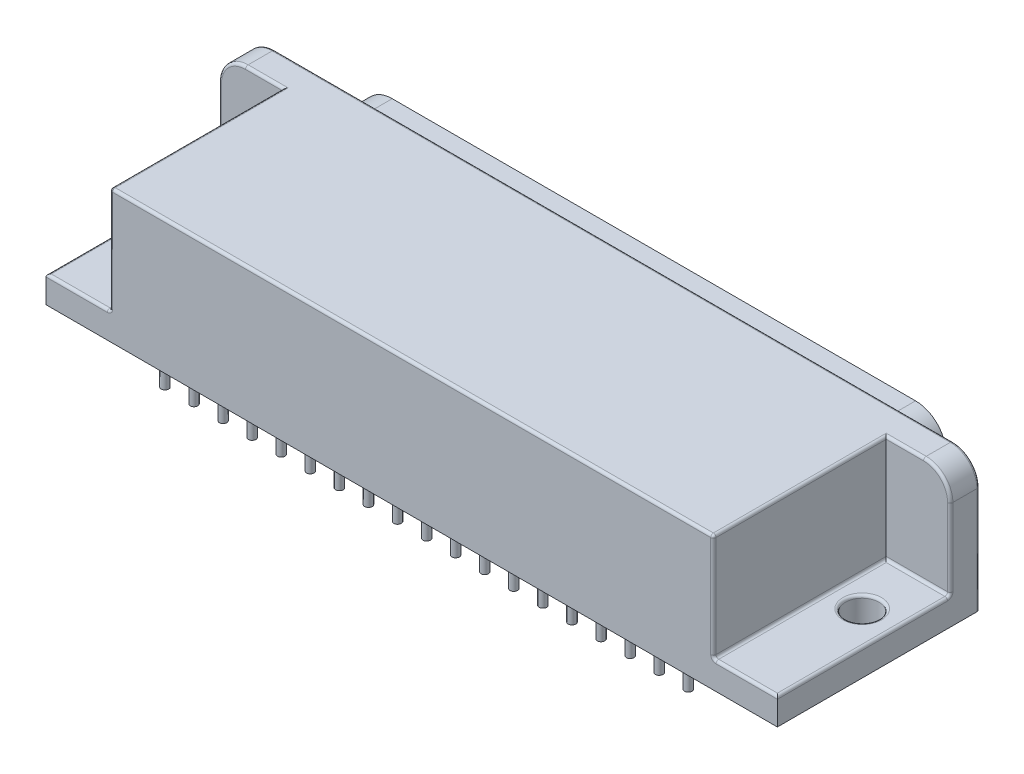
from build123d import *

# Parameters (mm, degrees)
SKETCH1_W              = 69.6468
SKETCH1_H              = 19.2532
BASE_EXTRUDE_DEPTH     = 12.7
BOSS_EXTRUDE1_DEPTH    = 3.81
CUT_EXTRUDE5_DEPTH     = 3.81
SKETCH4_R              = 0.508
BOSS_EXTRUDE4_DEPTH    = 3.81
FILLET7_R              = 0.4826
LPATTERN5_COUNT        = 19
LPATTERN5_PITCH        = 2.7686
FILLET7_OF_LPATTERN5_R = 0.4826
SKETCH5_R              = 0.508
BOSS_EXTRUDE6_DEPTH    = 3.81
FILLET8_R              = 0.4826
LPATTERN6_COUNT        = 18
LPATTERN6_PITCH        = 2.7686
FILLET8_OF_LPATTERN6_R = 0.4826
SKETCH6_R              = 0.3556
BOSS_EXTRUDE2_DEPTH    = 2.54
LPATTERN1_COUNT        = 19
LPATTERN1_PITCH        = 2.7686
SKETCH7_R              = 0.3556
BOSS_EXTRUDE3_DEPTH    = 2.54
LPATTERN4_COUNT        = 18
LPATTERN4_PITCH        = 2.7686
SKETCH9_W              = 6.096
SKETCH9_H              = 10.16
CUT_EXTRUDE3_DEPTH     = 16.4592
SKETCH11_R             = 1.5875
CUT_EXTRUDE4_DEPTH     = 6.08
FILLET1_R              = 2.54
FILLET2_R              = 0.254


with BuildPart() as part:
    # Sketch1 → Base-Extrude (new body)
    with BuildSketch(Plane(origin=(0, 0, 0), x_dir=(1, 0, 0), z_dir=(0, 1, 0))):
        with Locations((24.9174, 8.2042)):
            Rectangle(SKETCH1_W, SKETCH1_H)
    extrude(amount=BASE_EXTRUDE_DEPTH)

    # Sketch2 → Boss-Extrude1 (add)
    with BuildSketch(Plane(origin=(0, 0, -17.8308), x_dir=(-1, 0, 0), z_dir=(0, 0, -1))):
        with BuildLine():
            Line((-49.339256541, 2.032), (-0.495543459, 2.032))
            ThreePointArc((-0.495543459, 2.032), (1.356379212, 2.697364324), (2.361406418, 4.389182158))
            Line((2.361406418, 4.389182158), (2.857115993, 6.951322085))
            ThreePointArc((2.857115993, 6.951322085), (2.244731828, 9.355992635), (0.000166116, 10.414))
            Line((0.000166116, 10.414), (-49.834966116, 10.414))
            ThreePointArc((-49.834966116, 10.414), (-52.079531828, 9.355992635), (-52.691915993, 6.951322085))
            Line((-52.691915993, 6.951322085), (-52.196206418, 4.389182158))
            ThreePointArc((-52.196206418, 4.389182158), (-51.191179212, 2.697364324), (-49.339256541, 2.032))
        make_face()
    extrude(amount=BOSS_EXTRUDE1_DEPTH)

    # Sketch13 → Cut-Extrude5 (cut)
    with BuildSketch(Plane(origin=(0, 0, -21.6408), x_dir=(-1, 0, 0), z_dir=(0, 0, -1))):
        with BuildLine():
            Line((2.112030914, 4.43743004), (2.607740489, 6.999569967))
            ThreePointArc((2.607740489, 6.999569967), (2.048809698, 9.194343265), (0.000166116, 10.16))
            Line((0.000166116, 10.16), (-49.834966116, 10.16))
            ThreePointArc((-49.834966116, 10.16), (-51.883609698, 9.194343265), (-52.442540489, 6.999569967))
            Line((-52.442540489, 6.999569967), (-51.946830914, 4.43743004))
            ThreePointArc((-51.946830914, 4.43743004), (-51.029529842, 2.893286454), (-49.339256541, 2.286))
            Line((-49.339256541, 2.286), (-0.495543459, 2.286))
            ThreePointArc((-0.495543459, 2.286), (1.194729842, 2.893286454), (2.112030914, 4.43743004))
        make_face()
    extrude(amount=-CUT_EXTRUDE5_DEPTH, mode=Mode.SUBTRACT)

    # Sketch4 → Boss-Extrude4 (add)
    with BuildSketch(Plane(origin=(0, 0, -17.8308), x_dir=(-1, 0, 0), z_dir=(0, 0, -1))):
        with Locations((-0.254, 7.62)):
            Circle(SKETCH4_R)
    boss_extrude4 = extrude(amount=BOSS_EXTRUDE4_DEPTH)

    # Fillet7
    fillet7_edges = [part.edges().sort_by_distance(p)[0] for p in [
        (0.762, 7.62, -21.6408),
    ]]
    fillet(fillet7_edges, radius=FILLET7_R)

    # LPattern5: Boss-Extrude4 ×19
    with Locations(*[(i * LPATTERN5_PITCH, 0, 0) for i in range(1, LPATTERN5_COUNT)]):
        add(boss_extrude4)

    # Fillet7 of LPattern5
    fillet7_of_lpattern5_edges = [part.edges().sort_by_distance(p)[0] for p in [
        (3.5306, 7.62, -21.6408),
        (6.2992, 7.62, -21.6408),
        (9.0678, 7.62, -21.6408),
        (11.8364, 7.62, -21.6408),
        (14.605, 7.62, -21.6408),
        (17.3736, 7.62, -21.6408),
        (20.1422, 7.62, -21.6408),
        (22.9108, 7.62, -21.6408),
        (25.6794, 7.62, -21.6408),
        (28.448, 7.62, -21.6408),
        (31.2166, 7.62, -21.6408),
        (33.9852, 7.62, -21.6408),
        (36.7538, 7.62, -21.6408),
        (39.5224, 7.62, -21.6408),
        (42.291, 7.62, -21.6408),
        (45.0596, 7.62, -21.6408),
        (47.8282, 7.62, -21.6408),
        (50.5968, 7.62, -21.6408),
    ]]
    fillet(fillet7_of_lpattern5_edges, radius=FILLET7_OF_LPATTERN5_R)

    # Sketch5 → Boss-Extrude6 (add)
    with BuildSketch(Plane(origin=(0, 0, -17.8308), x_dir=(-1, 0, 0), z_dir=(0, 0, -1))):
        with Locations((-1.651, 5.08)):
            Circle(SKETCH5_R)
    boss_extrude6 = extrude(amount=BOSS_EXTRUDE6_DEPTH)

    # Fillet8
    fillet8_edges = [part.edges().sort_by_distance(p)[0] for p in [
        (2.159, 5.08, -21.6408),
    ]]
    fillet(fillet8_edges, radius=FILLET8_R)

    # LPattern6: Boss-Extrude6 ×18
    with Locations(*[(i * LPATTERN6_PITCH, 0, 0) for i in range(1, LPATTERN6_COUNT)]):
        add(boss_extrude6)

    # Fillet8 of LPattern6
    fillet8_of_lpattern6_edges = [part.edges().sort_by_distance(p)[0] for p in [
        (4.9276, 5.08, -21.6408),
        (7.6962, 5.08, -21.6408),
        (10.4648, 5.08, -21.6408),
        (13.2334, 5.08, -21.6408),
        (16.002, 5.08, -21.6408),
        (18.7706, 5.08, -21.6408),
        (21.5392, 5.08, -21.6408),
        (24.3078, 5.08, -21.6408),
        (27.0764, 5.08, -21.6408),
        (29.845, 5.08, -21.6408),
        (32.6136, 5.08, -21.6408),
        (35.3822, 5.08, -21.6408),
        (38.1508, 5.08, -21.6408),
        (40.9194, 5.08, -21.6408),
        (43.688, 5.08, -21.6408),
        (46.4566, 5.08, -21.6408),
        (49.2252, 5.08, -21.6408),
    ]]
    fillet(fillet8_of_lpattern6_edges, radius=FILLET8_OF_LPATTERN6_R)

    # Sketch6 → Boss-Extrude2 (add)
    with BuildSketch(Plane.XZ):
        Circle(SKETCH6_R)
    boss_extrude2 = extrude(amount=BOSS_EXTRUDE2_DEPTH)

    # LPattern1: Boss-Extrude2 ×19
    with Locations(*[(i * LPATTERN1_PITCH, 0, 0) for i in range(1, LPATTERN1_COUNT)]):
        add(boss_extrude2)

    # Sketch7 → Boss-Extrude3 (add)
    with BuildSketch(Plane.XZ):
        with Locations((1.651, -2.54)):
            Circle(SKETCH7_R)
    boss_extrude3 = extrude(amount=BOSS_EXTRUDE3_DEPTH)

    # LPattern4: Boss-Extrude3 ×18
    with Locations(*[(i * LPATTERN4_PITCH, 0, 0) for i in range(1, LPATTERN4_COUNT)]):
        add(boss_extrude3)

    # Sketch9 → Cut-Extrude3 (cut)
    with BuildSketch(Plane.XY.offset(1.4224)):
        with Locations((-6.858, 7.62)):
            Rectangle(SKETCH9_W, SKETCH9_H)
    cut_extrude3 = extrude(amount=-CUT_EXTRUDE3_DEPTH, mode=Mode.SUBTRACT)

    # Sketch11 → Cut-Extrude4 (cut, through all)
    with BuildSketch(Plane(origin=(0, 2.54, 0), x_dir=(-1, 0, 0), z_dir=(0, 1, 0))):
        with Locations((6.731, -9.8298)):
            Circle(SKETCH11_R)
    cut_extrude4 = extrude(amount=-CUT_EXTRUDE4_DEPTH, mode=Mode.SUBTRACT)

    # Mirror1: Cut-Extrude3, Cut-Extrude4 across plane
    add(cut_extrude3.mirror(Plane(origin=(24.9174, 0, 0), x_dir=(0, 0, 1), z_dir=(1, 0, 0))), mode=Mode.SUBTRACT)
    add(cut_extrude4.mirror(Plane(origin=(24.9174, 0, 0), x_dir=(0, 0, 1), z_dir=(1, 0, 0))), mode=Mode.SUBTRACT)

    # Fillet1
    fillet1_edges = [part.edges().sort_by_distance(p)[0] for p in [
        (-9.906, 12.7, -16.4338),
        (59.7408, 12.7, -16.4338),
    ]]
    fillet(fillet1_edges, radius=FILLET1_R)

    # Fillet2
    fillet2_edges = [part.edges().sort_by_distance(p)[0] for p in [
        (24.9174, 12.7, 1.4224),
        (-9.906, 2.54, -6.8072),
        (-5.588, 12.7, -15.0368),
        (-3.81, 12.7, -6.8072),
        (-6.858, 2.54, -15.0368),
        (-3.81, 2.54, -6.8072),
        (-6.858, 2.54, 1.4224),
        (-3.81, 7.62, 1.4224),
        (-5.1435, 2.54, -9.8298),
        (56.6928, 2.54, 1.4224),
        (59.7408, 2.54, -6.8072),
        (53.6448, 7.62, 1.4224),
        (53.6448, 2.54, -6.8072),
        (53.6448, 12.7, -6.8072),
        (56.6928, 2.54, -15.0368),
        (55.4228, 12.7, -15.0368),
        (54.9783, 2.54, -9.8298),
        (24.9174, 12.7, -17.8308),
        (-9.906, 6.35, -15.0368),
        (-9.162051224, 11.956051224, -15.0368),
        (-9.906, 5.08, -17.8308),
        (59.7408, 5.08, -17.8308),
        (58.996851224, 11.956051224, -17.8308),
        (-9.162051224, 11.956051224, -17.8308),
        (59.7408, 6.35, -15.0368),
        (58.996851224, 11.956051224, -15.0368),
    ]]
    fillet(fillet2_edges, radius=FILLET2_R)


solid = part.part
